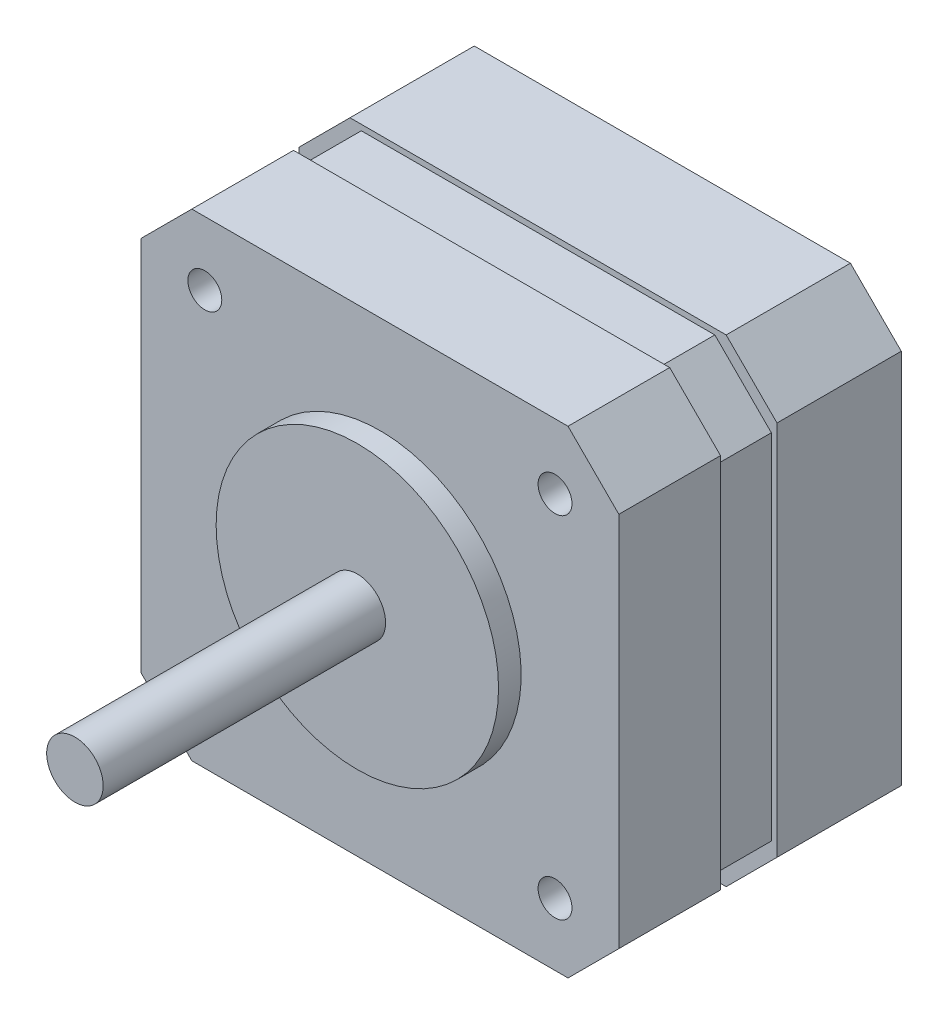
from build123d import *

# Parameters (mm, degrees)
ESQUISSE1_W             = 42.3
ESQUISSE1_H             = 42.3
BOSS_EXTRU_1_DEPTH      = 11
ESQUISSE2_W             = 41.3
ESQUISSE2_H             = 41.3
BOSS_EXTRU_2_DEPTH      = 5
ESQUISSE3_W             = 42.3
ESQUISSE3_H             = 42.3
BOSS_EXTRU_3_DEPTH      = 9
ESQUISSE4_R             = 12.5
BOSS_EXTRU_4_DEPTH      = 2
ESQUISSE5_R             = 2.5
BOSS_EXTRU_5_DEPTH      = 25
ESQUISSE6_R             = 1.5
ENL_V_MAT_EXTRU_1_DEPTH = 15
CHANFREIN2_SIZE         = 5
CHANFREIN3_SIZE         = 4.5


with BuildPart() as part:
    # Esquisse1 → Boss.-Extru.1 (new body)
    with BuildSketch(Plane.XY):
        with Locations((21.15, 21.15)):
            Rectangle(ESQUISSE1_W, ESQUISSE1_H)
    extrude(amount=BOSS_EXTRU_1_DEPTH)

    # Esquisse2 → Boss.-Extru.2 (add)
    with BuildSketch(Plane.XY.offset(11)):
        with Locations((21.15, 21.15)):
            Rectangle(ESQUISSE2_W, ESQUISSE2_H)
    extrude(amount=BOSS_EXTRU_2_DEPTH)

    # Esquisse3 → Boss.-Extru.3 (add)
    with BuildSketch(Plane.XY.offset(16)):
        with Locations((21.15, 21.15)):
            Rectangle(ESQUISSE3_W, ESQUISSE3_H)
    extrude(amount=BOSS_EXTRU_3_DEPTH)

    # Esquisse4 → Boss.-Extru.4 (add)
    with BuildSketch(Plane.XY.offset(25)):
        with Locations(Location((21.15, 21.15, 0), (0, 0, 180))):  # turned: the seam where the file's is
            Circle(ESQUISSE4_R)
    extrude(amount=BOSS_EXTRU_4_DEPTH)

    # Esquisse5 → Boss.-Extru.5 (add)
    with BuildSketch(Plane.XY.offset(27)):
        with Locations((21.15, 21.15)):
            Circle(ESQUISSE5_R)
    extrude(amount=BOSS_EXTRU_5_DEPTH)

    # Esquisse6 → Enlèv. mat.-Extru.1 (cut)
    with BuildSketch(Plane.XY.offset(25)):
        with Locations((5.65, 36.65)):
            Circle(ESQUISSE6_R)
        with Locations((5.65, 5.65)):
            Circle(ESQUISSE6_R)
        with Locations((36.65, 5.536437172)):
            Circle(ESQUISSE6_R)
        with Locations((36.65, 36.536437172)):
            Circle(ESQUISSE6_R)
    extrude(amount=-ENL_V_MAT_EXTRU_1_DEPTH, mode=Mode.SUBTRACT)

    # Chanfrein2
    chanfrein2_edges = [part.edges().sort_by_distance(p)[0] for p in [
        (0.5, 41.8, 13.5),
        (0.5, 0.5, 13.5),
        (41.8, 0.5, 13.5),
        (41.8, 41.8, 13.5),
    ]]
    chamfer(chanfrein2_edges, length=CHANFREIN2_SIZE)

    # Chanfrein3
    chanfrein3_edges = [part.edges().sort_by_distance(p)[0] for p in [
        (0, 42.3, 20.5),
        (0, 0, 20.5),
        (42.3, 0, 20.5),
        (42.3, 42.3, 20.5),
        (0, 42.3, 5.5),
        (42.3, 42.3, 5.5),
        (42.3, 0, 5.5),
        (0, 0, 5.5),
    ]]
    chamfer(chanfrein3_edges, length=CHANFREIN3_SIZE)


solid = part.part
